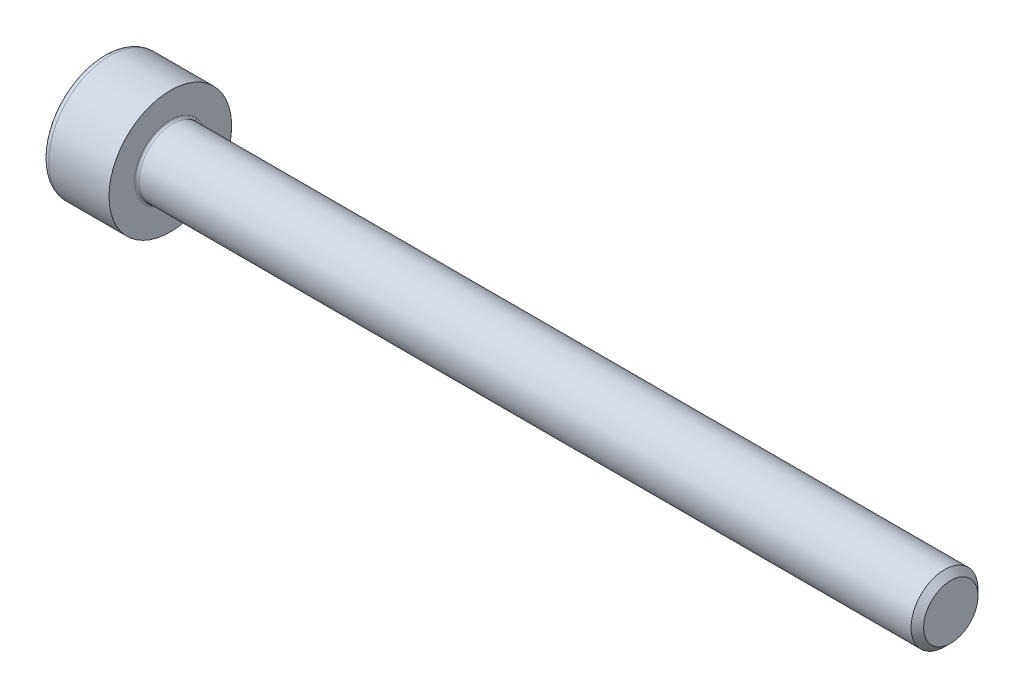
from build123d import *

# Parameters (mm, degrees)
FILLET1_R   = 0.1
FILLET2_R   = 0.3
HEX_2_DEPTH = 1.3


with BuildPart() as part:
    # BodySke → Base-Revolve (revolve)
    with BuildSketch(Plane.XY):
        Polygon((0, 0), (0, 2.75), (3, 2.75), (3, 1.5), (37.7195, 1.5), (38, 1.2195), (38, 0), align=None)
    revolve(axis=Axis((-31.75, 0, 0), (1, 0, 0)))

    # Fillet1
    fillet1_edges = [part.edges().sort_by_distance(p)[0] for p in [
        (3, -1.5, 0),
    ]]
    fillet(fillet1_edges, radius=FILLET1_R)

    # Fillet2
    fillet2_edges = [part.edges().sort_by_distance(p)[0] for p in [
        (0, -2.75, 0),
    ]]
    fillet(fillet2_edges, radius=FILLET2_R)

    # Sketch2 → Hex-PreBroach (revolve, cut)
    with BuildSketch(Plane.XY):
        Polygon((0, 1.26), (1.3, 1.26), (2.027461339, 0), (0, 0), align=None)
    revolve(axis=Axis((0, 0, 0), (1, 0, 0)), mode=Mode.SUBTRACT)

    # Sketch3 → Hex 2 (cut)
    with BuildSketch(Plane(origin=(0, 0, 0), x_dir=(0, 0.5, 0.866025404), z_dir=(-1, 0, 0))):
        Polygon((0.727461339, 1.26), (-0.727461339, 1.26), (-1.454922678, 0), (-0.727461339, -1.26), (0.727461339, -1.26), (1.454922678, 0), align=None)
    extrude(amount=-HEX_2_DEPTH, mode=Mode.SUBTRACT)


solid = part.part
